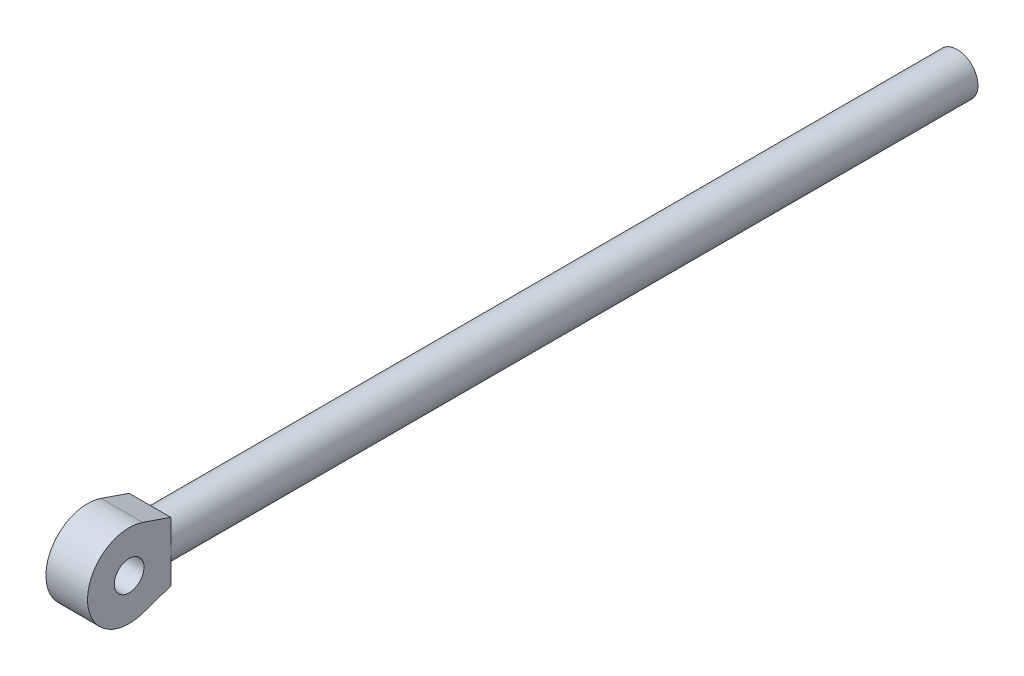
from build123d import *

# Parameters (mm, degrees)
SKETCH1_R           = 17.5
BOSS_EXTRUDE1_DEPTH = 679
BOSS_EXTRUDE3_DEPTH = 17.5
SKETCH5_R           = 12.5
CUT_EXTRUDE1_DEPTH  = 35


with BuildPart() as part:
    # Sketch1 → Boss-Extrude1 (new body)
    with BuildSketch(Plane.XY):
        Circle(SKETCH1_R)
    extrude(amount=BOSS_EXTRUDE1_DEPTH)

    # Sketch3 → Boss-Extrude3 (add, symmetric)
    with BuildSketch(Plane(origin=(0, 0, 0), x_dir=(0, 0, -1), z_dir=(1, 0, 0))):
        with BuildLine():
            Line((-679, 0), (-749, 0))
            ThreePointArc((-749, 0), (-734.34333678, 28.480671492), (-702.648648649, 33.108108108))
            Line((-702.648648649, 33.108108108), (-679, 25))
            Line((-679, 25), (-679, 0))
        make_face()
    boss_extrude3 = extrude(amount=BOSS_EXTRUDE3_DEPTH, both=True)

    # Mirror3: Boss-Extrude3 across plane
    add(boss_extrude3.mirror(Plane(origin=(17.5, 0, 679), x_dir=(0, 0, 1), z_dir=(0, 1, 0))))

    # Sketch5 → Cut-Extrude1 (cut)
    with BuildSketch(Plane(origin=(17.5, 0, 0), x_dir=(0, 0, -1), z_dir=(1, 0, 0))):
        with Locations((-714, 0)):
            Circle(SKETCH5_R)
    extrude(amount=-CUT_EXTRUDE1_DEPTH, mode=Mode.SUBTRACT)


solid = part.part
